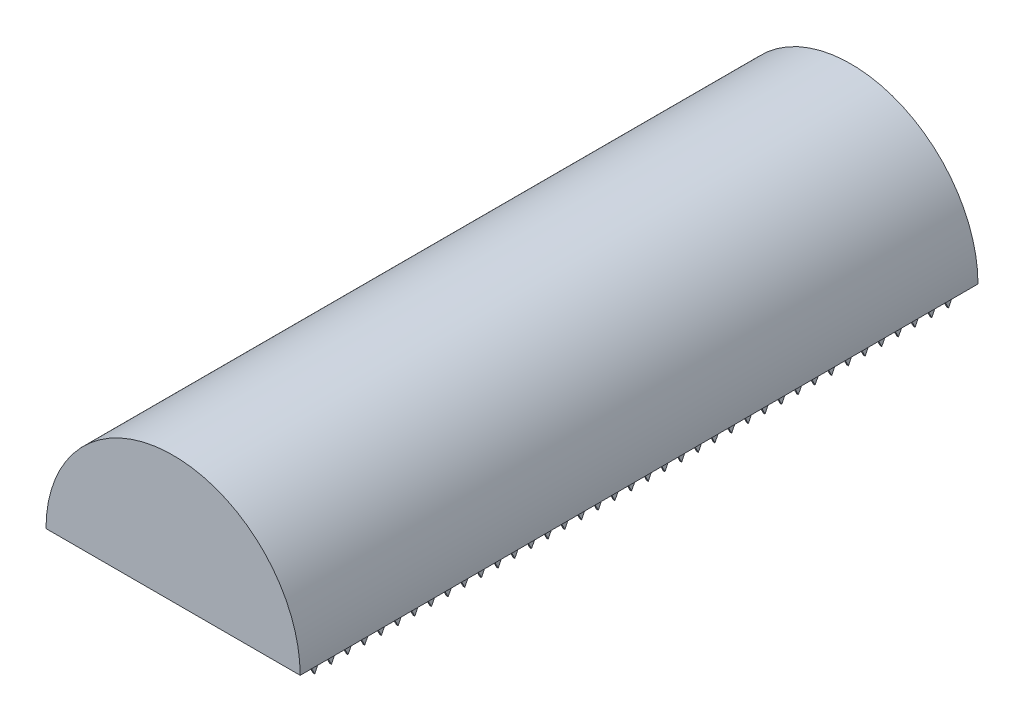
from build123d import *

# Parameters (mm, degrees)
BOSS_EXTRUDE1_DEPTH    = 406.4
SHELL1_T               = -6.35
BOSS_EXTRUDE2_DEPTH    = 1
BOSS_EXTRUDE2_2_DEPTH  = 1
BOSS_EXTRUDE2_3_DEPTH  = 1
BOSS_EXTRUDE2_4_DEPTH  = 1
BOSS_EXTRUDE2_5_DEPTH  = 1
BOSS_EXTRUDE2_6_DEPTH  = 1
BOSS_EXTRUDE2_7_DEPTH  = 1
BOSS_EXTRUDE2_8_DEPTH  = 1
BOSS_EXTRUDE2_9_DEPTH  = 1
BOSS_EXTRUDE2_10_DEPTH = 1
BOSS_EXTRUDE2_11_DEPTH = 1
BOSS_EXTRUDE2_12_DEPTH = 1
BOSS_EXTRUDE2_13_DEPTH = 1
BOSS_EXTRUDE2_14_DEPTH = 1
BOSS_EXTRUDE2_15_DEPTH = 1
BOSS_EXTRUDE2_16_DEPTH = 1
BOSS_EXTRUDE2_17_DEPTH = 1
BOSS_EXTRUDE2_18_DEPTH = 1
BOSS_EXTRUDE2_19_DEPTH = 1
BOSS_EXTRUDE2_20_DEPTH = 1
BOSS_EXTRUDE2_21_DEPTH = 1
BOSS_EXTRUDE2_22_DEPTH = 1
BOSS_EXTRUDE2_23_DEPTH = 1
BOSS_EXTRUDE2_24_DEPTH = 1
BOSS_EXTRUDE2_25_DEPTH = 1
BOSS_EXTRUDE2_26_DEPTH = 1
BOSS_EXTRUDE2_27_DEPTH = 1
BOSS_EXTRUDE2_28_DEPTH = 1
BOSS_EXTRUDE2_29_DEPTH = 1
BOSS_EXTRUDE2_30_DEPTH = 1
BOSS_EXTRUDE2_31_DEPTH = 1
BOSS_EXTRUDE2_32_DEPTH = 1
BOSS_EXTRUDE2_33_DEPTH = 1
BOSS_EXTRUDE2_34_DEPTH = 1
BOSS_EXTRUDE2_35_DEPTH = 1
BOSS_EXTRUDE2_36_DEPTH = 1
BOSS_EXTRUDE2_37_DEPTH = 1
BOSS_EXTRUDE2_38_DEPTH = 1
BOSS_EXTRUDE2_39_DEPTH = 1


with BuildPart() as part:
    # Sketch1 → Boss-Extrude1 (new body)
    with BuildSketch(Plane.XY):
        with BuildLine():
            Line((-76.2, 0), (76.2, 0))
            ThreePointArc((76.2, 0), (0, 76.2), (-76.2, 0))
        make_face()
    extrude(amount=BOSS_EXTRUDE1_DEPTH)

    # Shell1
    shell1_openings = [part.faces().sort_by_distance(p)[0] for p in [
        (0, 0, 203.2),
    ]]
    offset(amount=SHELL1_T, openings=shell1_openings)


with BuildPart() as body_2:
    # Sketch3 → Boss-Extrude2 (new body)
    with BuildSketch(Plane(origin=(69.85, 0, 0), x_dir=(0, 0, -1), z_dir=(1, 0, 0))):
        Polygon((-11.35, -10), (-6.35, 0), (-16.35, 0), align=None)
    extrude(amount=-BOSS_EXTRUDE2_DEPTH)


with BuildPart() as body_3:
    # Sketch3 → Boss-Extrude2 2 (new body)
    with BuildSketch(Plane(origin=(69.85, 0, 0), x_dir=(0, 0, -1), z_dir=(1, 0, 0))):
        Polygon((-21.35, -10), (-16.35, 0), (-26.35, 0), align=None)
    extrude(amount=-BOSS_EXTRUDE2_2_DEPTH)


with BuildPart() as body_4:
    # Sketch3 → Boss-Extrude2 3 (new body)
    with BuildSketch(Plane(origin=(69.85, 0, 0), x_dir=(0, 0, -1), z_dir=(1, 0, 0))):
        Polygon((-31.35, -10), (-26.35, 0), (-36.35, 0), align=None)
    extrude(amount=-BOSS_EXTRUDE2_3_DEPTH)


with BuildPart() as body_5:
    # Sketch3 → Boss-Extrude2 4 (new body)
    with BuildSketch(Plane(origin=(69.85, 0, 0), x_dir=(0, 0, -1), z_dir=(1, 0, 0))):
        Polygon((-41.35, -10), (-36.35, 0), (-46.35, 0), align=None)
    extrude(amount=-BOSS_EXTRUDE2_4_DEPTH)


with BuildPart() as body_6:
    # Sketch3 → Boss-Extrude2 5 (new body)
    with BuildSketch(Plane(origin=(69.85, 0, 0), x_dir=(0, 0, -1), z_dir=(1, 0, 0))):
        Polygon((-51.35, -10), (-46.35, 0), (-56.35, 0), align=None)
    extrude(amount=-BOSS_EXTRUDE2_5_DEPTH)


with BuildPart() as body_7:
    # Sketch3 → Boss-Extrude2 6 (new body)
    with BuildSketch(Plane(origin=(69.85, 0, 0), x_dir=(0, 0, -1), z_dir=(1, 0, 0))):
        Polygon((-61.35, -10), (-56.35, 0), (-66.35, 0), align=None)
    extrude(amount=-BOSS_EXTRUDE2_6_DEPTH)


with BuildPart() as body_8:
    # Sketch3 → Boss-Extrude2 7 (new body)
    with BuildSketch(Plane(origin=(69.85, 0, 0), x_dir=(0, 0, -1), z_dir=(1, 0, 0))):
        Polygon((-71.35, -10), (-66.35, 0), (-76.35, 0), align=None)
    extrude(amount=-BOSS_EXTRUDE2_7_DEPTH)


with BuildPart() as body_9:
    # Sketch3 → Boss-Extrude2 8 (new body)
    with BuildSketch(Plane(origin=(69.85, 0, 0), x_dir=(0, 0, -1), z_dir=(1, 0, 0))):
        Polygon((-81.35, -10), (-76.35, 0), (-86.35, 0), align=None)
    extrude(amount=-BOSS_EXTRUDE2_8_DEPTH)


with BuildPart() as body_10:
    # Sketch3 → Boss-Extrude2 9 (new body)
    with BuildSketch(Plane(origin=(69.85, 0, 0), x_dir=(0, 0, -1), z_dir=(1, 0, 0))):
        Polygon((-91.35, -10), (-86.35, 0), (-96.35, 0), align=None)
    extrude(amount=-BOSS_EXTRUDE2_9_DEPTH)


with BuildPart() as body_11:
    # Sketch3 → Boss-Extrude2 10 (new body)
    with BuildSketch(Plane(origin=(69.85, 0, 0), x_dir=(0, 0, -1), z_dir=(1, 0, 0))):
        Polygon((-101.35, -10), (-96.35, 0), (-106.35, 0), align=None)
    extrude(amount=-BOSS_EXTRUDE2_10_DEPTH)


with BuildPart() as body_12:
    # Sketch3 → Boss-Extrude2 11 (new body)
    with BuildSketch(Plane(origin=(69.85, 0, 0), x_dir=(0, 0, -1), z_dir=(1, 0, 0))):
        Polygon((-111.35, -10), (-106.35, 0), (-116.35, 0), align=None)
    extrude(amount=-BOSS_EXTRUDE2_11_DEPTH)


with BuildPart() as body_13:
    # Sketch3 → Boss-Extrude2 12 (new body)
    with BuildSketch(Plane(origin=(69.85, 0, 0), x_dir=(0, 0, -1), z_dir=(1, 0, 0))):
        Polygon((-121.35, -10), (-116.35, 0), (-126.35, 0), align=None)
    extrude(amount=-BOSS_EXTRUDE2_12_DEPTH)


with BuildPart() as body_14:
    # Sketch3 → Boss-Extrude2 13 (new body)
    with BuildSketch(Plane(origin=(69.85, 0, 0), x_dir=(0, 0, -1), z_dir=(1, 0, 0))):
        Polygon((-131.35, -10), (-126.35, 0), (-136.35, 0), align=None)
    extrude(amount=-BOSS_EXTRUDE2_13_DEPTH)


with BuildPart() as body_15:
    # Sketch3 → Boss-Extrude2 14 (new body)
    with BuildSketch(Plane(origin=(69.85, 0, 0), x_dir=(0, 0, -1), z_dir=(1, 0, 0))):
        Polygon((-141.35, -10), (-136.35, 0), (-146.35, 0), align=None)
    extrude(amount=-BOSS_EXTRUDE2_14_DEPTH)


with BuildPart() as body_16:
    # Sketch3 → Boss-Extrude2 15 (new body)
    with BuildSketch(Plane(origin=(69.85, 0, 0), x_dir=(0, 0, -1), z_dir=(1, 0, 0))):
        Polygon((-151.35, -10), (-146.35, 0), (-156.35, 0), align=None)
    extrude(amount=-BOSS_EXTRUDE2_15_DEPTH)


with BuildPart() as body_17:
    # Sketch3 → Boss-Extrude2 16 (new body)
    with BuildSketch(Plane(origin=(69.85, 0, 0), x_dir=(0, 0, -1), z_dir=(1, 0, 0))):
        Polygon((-161.35, -10), (-156.35, 0), (-166.35, 0), align=None)
    extrude(amount=-BOSS_EXTRUDE2_16_DEPTH)


with BuildPart() as body_18:
    # Sketch3 → Boss-Extrude2 17 (new body)
    with BuildSketch(Plane(origin=(69.85, 0, 0), x_dir=(0, 0, -1), z_dir=(1, 0, 0))):
        Polygon((-171.35, -10), (-166.35, 0), (-176.35, 0), align=None)
    extrude(amount=-BOSS_EXTRUDE2_17_DEPTH)


with BuildPart() as body_19:
    # Sketch3 → Boss-Extrude2 18 (new body)
    with BuildSketch(Plane(origin=(69.85, 0, 0), x_dir=(0, 0, -1), z_dir=(1, 0, 0))):
        Polygon((-181.35, -10), (-176.35, 0), (-186.35, 0), align=None)
    extrude(amount=-BOSS_EXTRUDE2_18_DEPTH)


with BuildPart() as body_20:
    # Sketch3 → Boss-Extrude2 19 (new body)
    with BuildSketch(Plane(origin=(69.85, 0, 0), x_dir=(0, 0, -1), z_dir=(1, 0, 0))):
        Polygon((-191.35, -10), (-186.35, 0), (-196.35, 0), align=None)
    extrude(amount=-BOSS_EXTRUDE2_19_DEPTH)


with BuildPart() as body_21:
    # Sketch3 → Boss-Extrude2 20 (new body)
    with BuildSketch(Plane(origin=(69.85, 0, 0), x_dir=(0, 0, -1), z_dir=(1, 0, 0))):
        Polygon((-201.35, -10), (-196.35, 0), (-206.35, 0), align=None)
    extrude(amount=-BOSS_EXTRUDE2_20_DEPTH)


with BuildPart() as body_22:
    # Sketch3 → Boss-Extrude2 21 (new body)
    with BuildSketch(Plane(origin=(69.85, 0, 0), x_dir=(0, 0, -1), z_dir=(1, 0, 0))):
        Polygon((-211.35, -10), (-206.35, 0), (-216.35, 0), align=None)
    extrude(amount=-BOSS_EXTRUDE2_21_DEPTH)


with BuildPart() as body_23:
    # Sketch3 → Boss-Extrude2 22 (new body)
    with BuildSketch(Plane(origin=(69.85, 0, 0), x_dir=(0, 0, -1), z_dir=(1, 0, 0))):
        Polygon((-221.35, -10), (-216.35, 0), (-226.35, 0), align=None)
    extrude(amount=-BOSS_EXTRUDE2_22_DEPTH)


with BuildPart() as body_24:
    # Sketch3 → Boss-Extrude2 23 (new body)
    with BuildSketch(Plane(origin=(69.85, 0, 0), x_dir=(0, 0, -1), z_dir=(1, 0, 0))):
        Polygon((-231.35, -10), (-226.35, 0), (-236.35, 0), align=None)
    extrude(amount=-BOSS_EXTRUDE2_23_DEPTH)


with BuildPart() as body_25:
    # Sketch3 → Boss-Extrude2 24 (new body)
    with BuildSketch(Plane(origin=(69.85, 0, 0), x_dir=(0, 0, -1), z_dir=(1, 0, 0))):
        Polygon((-241.35, -10), (-236.35, 0), (-246.35, 0), align=None)
    extrude(amount=-BOSS_EXTRUDE2_24_DEPTH)


with BuildPart() as body_26:
    # Sketch3 → Boss-Extrude2 25 (new body)
    with BuildSketch(Plane(origin=(69.85, 0, 0), x_dir=(0, 0, -1), z_dir=(1, 0, 0))):
        Polygon((-251.35, -10), (-246.35, 0), (-256.35, 0), align=None)
    extrude(amount=-BOSS_EXTRUDE2_25_DEPTH)


with BuildPart() as body_27:
    # Sketch3 → Boss-Extrude2 26 (new body)
    with BuildSketch(Plane(origin=(69.85, 0, 0), x_dir=(0, 0, -1), z_dir=(1, 0, 0))):
        Polygon((-261.35, -10), (-256.35, 0), (-266.35, 0), align=None)
    extrude(amount=-BOSS_EXTRUDE2_26_DEPTH)


with BuildPart() as body_28:
    # Sketch3 → Boss-Extrude2 27 (new body)
    with BuildSketch(Plane(origin=(69.85, 0, 0), x_dir=(0, 0, -1), z_dir=(1, 0, 0))):
        Polygon((-271.35, -10), (-266.35, 0), (-276.35, 0), align=None)
    extrude(amount=-BOSS_EXTRUDE2_27_DEPTH)


with BuildPart() as body_29:
    # Sketch3 → Boss-Extrude2 28 (new body)
    with BuildSketch(Plane(origin=(69.85, 0, 0), x_dir=(0, 0, -1), z_dir=(1, 0, 0))):
        Polygon((-281.35, -10), (-276.35, 0), (-286.35, 0), align=None)
    extrude(amount=-BOSS_EXTRUDE2_28_DEPTH)


with BuildPart() as body_30:
    # Sketch3 → Boss-Extrude2 29 (new body)
    with BuildSketch(Plane(origin=(69.85, 0, 0), x_dir=(0, 0, -1), z_dir=(1, 0, 0))):
        Polygon((-291.35, -10), (-286.35, 0), (-296.35, 0), align=None)
    extrude(amount=-BOSS_EXTRUDE2_29_DEPTH)


with BuildPart() as body_31:
    # Sketch3 → Boss-Extrude2 30 (new body)
    with BuildSketch(Plane(origin=(69.85, 0, 0), x_dir=(0, 0, -1), z_dir=(1, 0, 0))):
        Polygon((-301.35, -10), (-296.35, 0), (-306.35, 0), align=None)
    extrude(amount=-BOSS_EXTRUDE2_30_DEPTH)


with BuildPart() as body_32:
    # Sketch3 → Boss-Extrude2 31 (new body)
    with BuildSketch(Plane(origin=(69.85, 0, 0), x_dir=(0, 0, -1), z_dir=(1, 0, 0))):
        Polygon((-311.35, -10), (-306.35, 0), (-316.35, 0), align=None)
    extrude(amount=-BOSS_EXTRUDE2_31_DEPTH)


with BuildPart() as body_33:
    # Sketch3 → Boss-Extrude2 32 (new body)
    with BuildSketch(Plane(origin=(69.85, 0, 0), x_dir=(0, 0, -1), z_dir=(1, 0, 0))):
        Polygon((-321.35, -10), (-316.35, 0), (-326.35, 0), align=None)
    extrude(amount=-BOSS_EXTRUDE2_32_DEPTH)


with BuildPart() as body_34:
    # Sketch3 → Boss-Extrude2 33 (new body)
    with BuildSketch(Plane(origin=(69.85, 0, 0), x_dir=(0, 0, -1), z_dir=(1, 0, 0))):
        Polygon((-331.35, -10), (-326.35, 0), (-336.35, 0), align=None)
    extrude(amount=-BOSS_EXTRUDE2_33_DEPTH)


with BuildPart() as body_35:
    # Sketch3 → Boss-Extrude2 34 (new body)
    with BuildSketch(Plane(origin=(69.85, 0, 0), x_dir=(0, 0, -1), z_dir=(1, 0, 0))):
        Polygon((-391.35, -10), (-386.35, 0), (-396.35, 0), align=None)
    extrude(amount=-BOSS_EXTRUDE2_34_DEPTH)


with BuildPart() as body_36:
    # Sketch3 → Boss-Extrude2 35 (new body)
    with BuildSketch(Plane(origin=(69.85, 0, 0), x_dir=(0, 0, -1), z_dir=(1, 0, 0))):
        Polygon((-381.35, -10), (-376.35, 0), (-386.35, 0), align=None)
    extrude(amount=-BOSS_EXTRUDE2_35_DEPTH)


with BuildPart() as body_37:
    # Sketch3 → Boss-Extrude2 36 (new body)
    with BuildSketch(Plane(origin=(69.85, 0, 0), x_dir=(0, 0, -1), z_dir=(1, 0, 0))):
        Polygon((-371.35, -10), (-366.35, 0), (-376.35, 0), align=None)
    extrude(amount=-BOSS_EXTRUDE2_36_DEPTH)


with BuildPart() as body_38:
    # Sketch3 → Boss-Extrude2 37 (new body)
    with BuildSketch(Plane(origin=(69.85, 0, 0), x_dir=(0, 0, -1), z_dir=(1, 0, 0))):
        Polygon((-361.35, -10), (-356.35, 0), (-366.35, 0), align=None)
    extrude(amount=-BOSS_EXTRUDE2_37_DEPTH)


with BuildPart() as body_39:
    # Sketch3 → Boss-Extrude2 38 (new body)
    with BuildSketch(Plane(origin=(69.85, 0, 0), x_dir=(0, 0, -1), z_dir=(1, 0, 0))):
        Polygon((-351.35, -10), (-346.35, 0), (-356.35, 0), align=None)
    extrude(amount=-BOSS_EXTRUDE2_38_DEPTH)


with BuildPart() as body_40:
    # Sketch3 → Boss-Extrude2 39 (new body)
    with BuildSketch(Plane(origin=(69.85, 0, 0), x_dir=(0, 0, -1), z_dir=(1, 0, 0))):
        Polygon((-341.35, -10), (-336.35, 0), (-346.35, 0), align=None)
    extrude(amount=-BOSS_EXTRUDE2_39_DEPTH)


solid = Compound([part.part, body_2.part, body_3.part, body_4.part, body_5.part, body_6.part, body_7.part, body_8.part, body_9.part, body_10.part, body_11.part, body_12.part, body_13.part, body_14.part, body_15.part, body_16.part, body_17.part, body_18.part, body_19.part, body_20.part, body_21.part, body_22.part, body_23.part, body_24.part, body_25.part, body_26.part, body_27.part, body_28.part, body_29.part, body_30.part, body_31.part, body_32.part, body_33.part, body_34.part, body_35.part, body_36.part, body_37.part, body_38.part, body_39.part, body_40.part])
